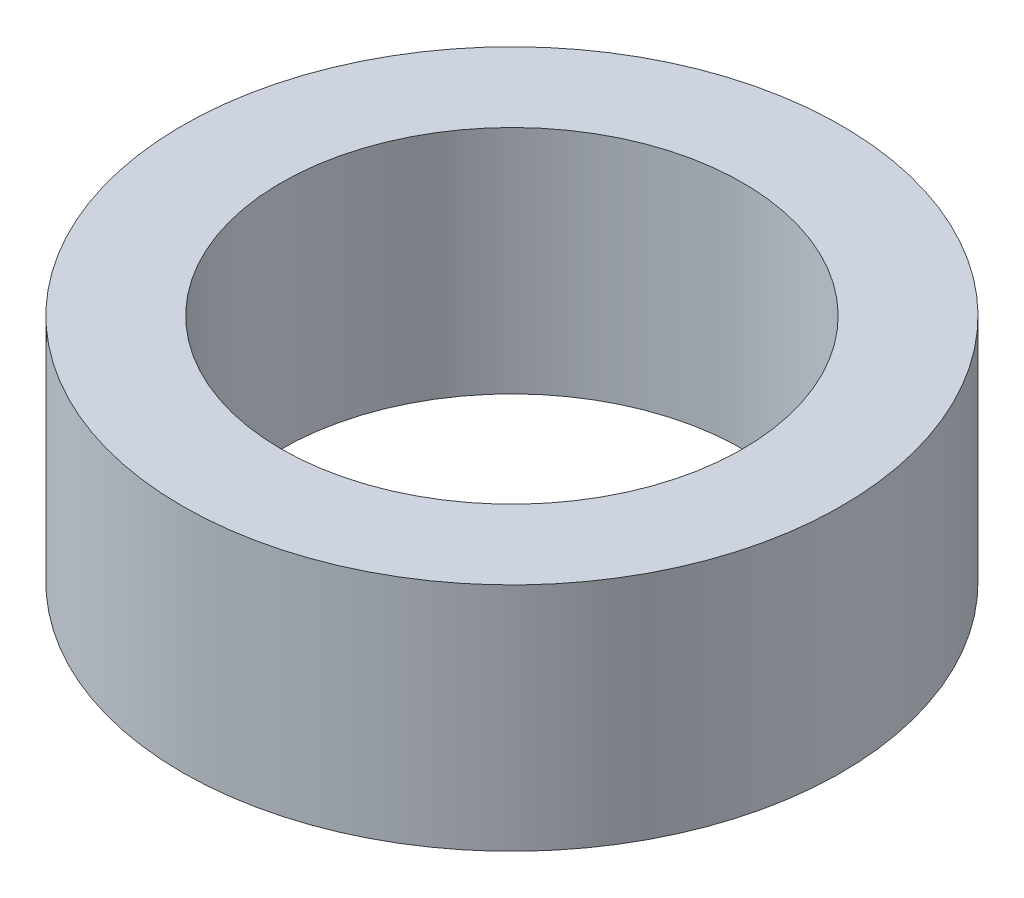
from build123d import *

# Parameters (mm, degrees)
SKETCH1_R           = 12.7
SKETCH1_R_2         = 8.89
BOSS_EXTRUDE1_DEPTH = 8.89


with BuildPart() as part:
    # Sketch1 → Boss-Extrude1 (new body)
    with BuildSketch(Plane(origin=(0, 0, 0), x_dir=(1, 0, 0), z_dir=(0, 1, 0))):
        Circle(SKETCH1_R)
        Circle(SKETCH1_R_2, mode=Mode.SUBTRACT)
    extrude(amount=BOSS_EXTRUDE1_DEPTH)


solid = part.part
